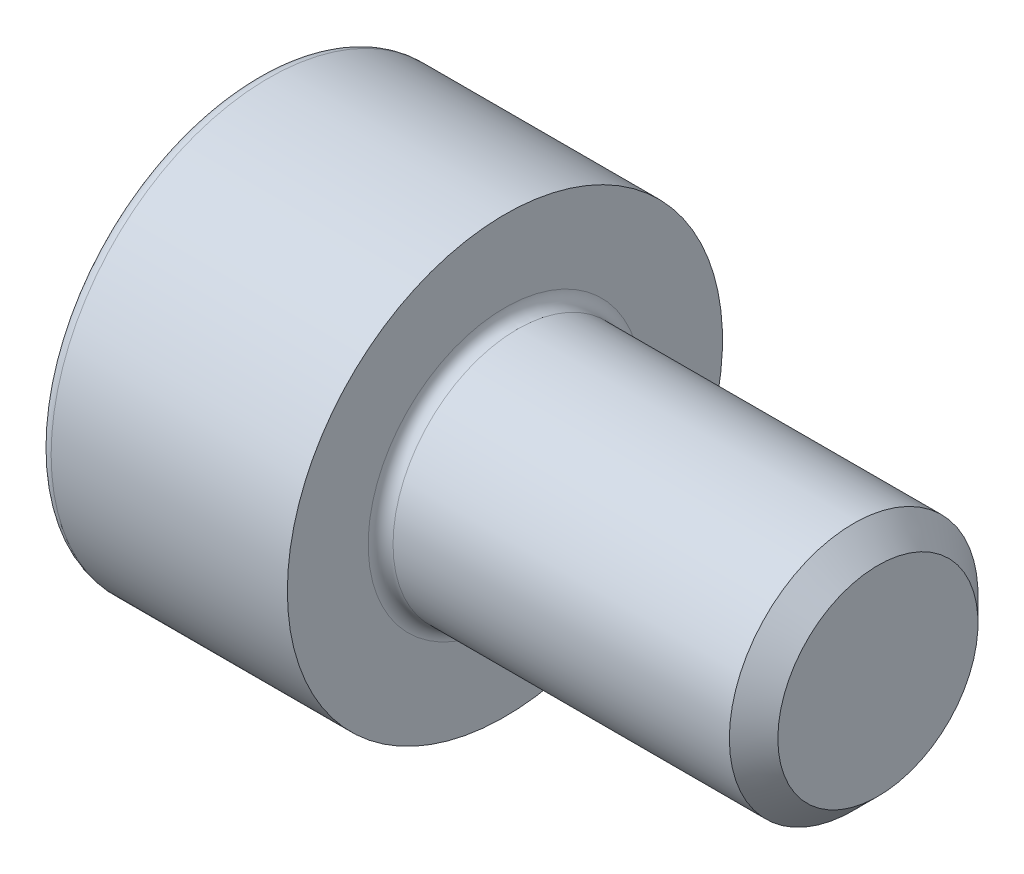
from build123d import *

# Parameters (mm, degrees)
FILLET1_R   = 0.2
FILLET2_R   = 0.2
HEX_2_DEPTH = 2


with BuildPart() as part:
    # BodySke → Base-Revolve (revolve)
    with BuildSketch(Plane.XY):
        Polygon((0, 0), (0, 3.5), (4, 3.5), (4, 2), (9.61, 2), (10, 1.61), (10, 0), align=None)
    revolve(axis=Axis((-31.75, 0, 0), (1, 0, 0)))

    # Fillet1
    fillet1_edges = [part.edges().sort_by_distance(p)[0] for p in [
        (4, -2, 0),
    ]]
    fillet(fillet1_edges, radius=FILLET1_R)

    # Fillet2
    fillet2_edges = [part.edges().sort_by_distance(p)[0] for p in [
        (0, -3.5, 0),
    ]]
    fillet(fillet2_edges, radius=FILLET2_R)

    # Sketch2 → Hex-PreBroach (revolve, cut)
    with BuildSketch(Plane.XY):
        Polygon((0, 1.5355), (2, 1.5355), (2.886521338, 0), (0, 0), align=None)
    revolve(axis=Axis((0, 0, 0), (1, 0, 0)), mode=Mode.SUBTRACT)

    # Sketch3 → Hex 2 (cut)
    with BuildSketch(Plane(origin=(0, 0, 0), x_dir=(0, 0.5, 0.866025404), z_dir=(-1, 0, 0))):
        Polygon((0.886521338, 1.5355), (-0.886521338, 1.5355), (-1.773042677, 0), (-0.886521338, -1.5355), (0.886521338, -1.5355), (1.773042677, 0), align=None)
    extrude(amount=-HEX_2_DEPTH, mode=Mode.SUBTRACT)


solid = part.part
